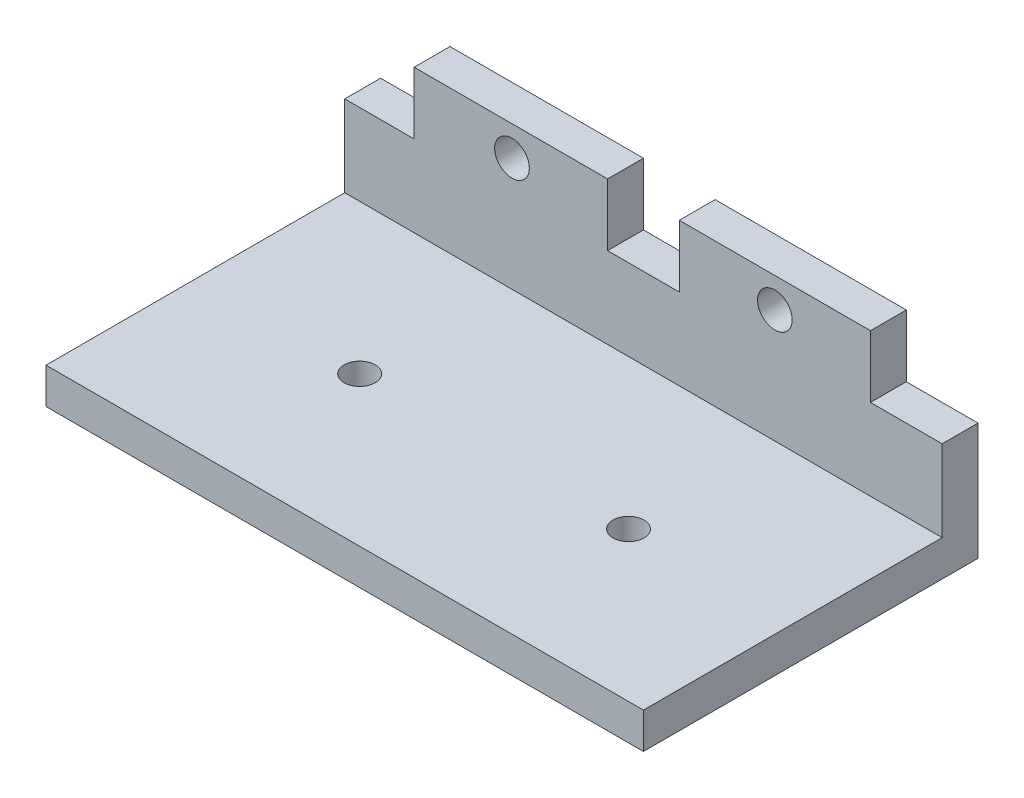
from build123d import *

# Parameters (mm, degrees)
SKETCH1_W           = 50
SKETCH1_H           = 28
BOSS_EXTRUDE1_DEPTH = 3
SKETCH2_W           = 50
SKETCH2_H           = 3
BOSS_EXTRUDE2_DEPTH = 12
SKETCH6_W           = 6
SKETCH6_H           = 5.2
CUT_EXTRUDE2_DEPTH  = 3
SKETCH7_R           = 1.3
CUT_EXTRUDE3_DEPTH  = 3
SKETCH8_R           = 1.45
CUT_EXTRUDE4_DEPTH  = 3


with BuildPart() as part:
    # Sketch1 → Boss-Extrude1 (new body)
    with BuildSketch(Plane(origin=(0, 0, 0), x_dir=(1, 0, 0), z_dir=(0, 1, 0))):
        Rectangle(SKETCH1_W, SKETCH1_H)
    extrude(amount=BOSS_EXTRUDE1_DEPTH)

    # Sketch2 → Boss-Extrude2 (add)
    with BuildSketch(Plane(origin=(0, 3, 0), x_dir=(1, 0, 0), z_dir=(0, 1, 0))):
        with Locations((0, 12.5)):
            Rectangle(SKETCH2_W, SKETCH2_H)
    extrude(amount=BOSS_EXTRUDE2_DEPTH)

    # Sketch6 → Cut-Extrude2 (cut)
    with BuildSketch(Plane(origin=(0, 0, -14), x_dir=(-1, 0, 0), z_dir=(0, 0, -1))):
        with Locations((-22, 12.4)):
            Rectangle(SKETCH6_W, SKETCH6_H)
        with Locations((0, 12.4)):
            Rectangle(SKETCH6_W, SKETCH6_H)
        with Locations((22.191038301, 12.4)):
            Rectangle(SKETCH6_W, SKETCH6_H)
    extrude(amount=-CUT_EXTRUDE2_DEPTH, mode=Mode.SUBTRACT)

    # Sketch7 → Cut-Extrude3 (cut)
    with BuildSketch(Plane.XZ):
        with Locations((-11.25, 1.5)):
            Circle(SKETCH7_R)
        with Locations((11.25, 1.5)):
            Circle(SKETCH7_R)
    extrude(amount=-CUT_EXTRUDE3_DEPTH, mode=Mode.SUBTRACT)

    # Sketch8 → Cut-Extrude4 (cut)
    with BuildSketch(Plane(origin=(0, 0, -14), x_dir=(-1, 0, 0), z_dir=(0, 0, -1))):
        with Locations((-11, 12.5)):
            Circle(SKETCH8_R)
        with Locations((11, 12.5)):
            Circle(SKETCH8_R)
    extrude(amount=-CUT_EXTRUDE4_DEPTH, mode=Mode.SUBTRACT)


solid = part.part
